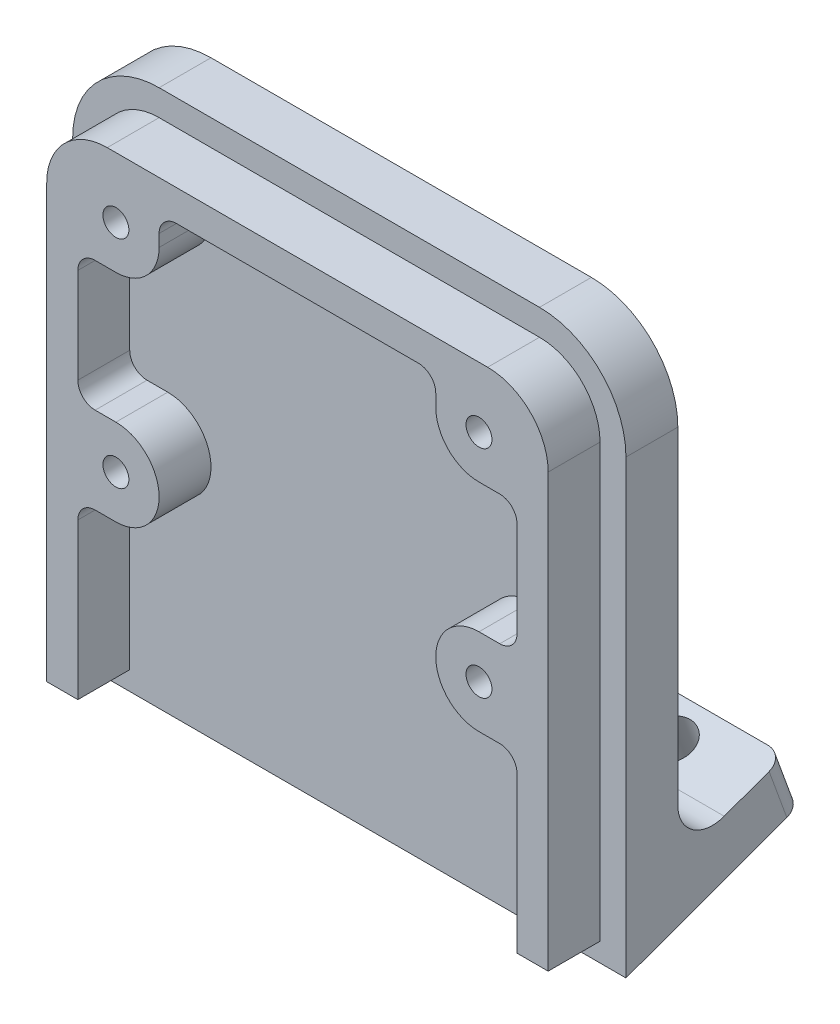
from build123d import *

# Parameters (mm, degrees)
SKETCH1_W                           = 32
SKETCH1_H                           = 30
BOSS_EXTRUDE1_DEPTH                 = 3
BOSS_EXTRUDE2_DEPTH                 = 3
F_1_5MM_CLEARANCE_DOWEL_HOLE1_D     = 1.5
F_1_5MM_CLEARANCE_DOWEL_HOLE1_DEPTH = 5
F_1_5MM_CLEARANCE_DOWEL_HOLE1_TIP   = 0.450645464
FILLET1_R                           = 5
FILLET2_R                           = 3.5
BOSS_EXTRUDE4_DEPTH                 = 32
BOSS_EXTRUDE5_DEPTH                 = 32
SKETCH8_R                           = 1.25
CUT_EXTRUDE1_DEPTH                  = 7.503603871
FILLET3_R                           = 1
FILLET4_R                           = 2
FILLET5_R                           = 1


with BuildPart() as part:
    # Sketch1 → Boss-Extrude1 (new body)
    with BuildSketch(Plane.XY):
        with Locations((16, 15)):
            Rectangle(SKETCH1_W, SKETCH1_H)
    extrude(amount=BOSS_EXTRUDE1_DEPTH)

    # Sketch2 → Boss-Extrude2 (add)
    with BuildSketch(Plane.XY.offset(3)):
        with BuildLine():
            Line((1.5, 0), (3.3, 0))
            Line((3.3, 0), (3.3, 10))
            Line((3.3, 10), (5.5, 10))
            ThreePointArc((5.5, 10), (8, 12.5), (5.5, 15))
            Line((5.5, 15), (3.3, 15))
            Line((3.3, 15), (3.3, 22.5))
            Line((3.3, 22.5), (5.5, 22.5))
            ThreePointArc((5.5, 22.5), (7.267766953, 23.232233047), (8, 25))
            Line((8, 25), (8, 26.7))
            Line((8, 26.7), (24, 26.7))
            Line((24, 26.7), (24, 25))
            ThreePointArc((24, 25), (24.732233047, 23.232233047), (26.5, 22.5))
            Line((26.5, 22.5), (28.7, 22.5))
            Line((28.7, 22.5), (28.7, 15))
            Line((28.7, 15), (26.5, 15))
            ThreePointArc((26.5, 15), (24, 12.5), (26.5, 10))
            Line((26.5, 10), (28.7, 10))
            Line((28.7, 10), (28.7, 0))
            Line((28.7, 0), (30.5, 0))
            Line((30.5, 0), (30.5, 28.5))
            Line((30.5, 28.5), (1.5, 28.5))
            Line((1.5, 28.5), (1.5, 0))
        make_face()
    extrude(amount=BOSS_EXTRUDE2_DEPTH)

    # Ø1.5mm Clearance Dowel Hole1
    with Locations(Plane(origin=(5.5, 25, 6), x_dir=(1, 0, 0), z_dir=(0, 0, 1))):
        with Locations((0, 0), (21, 0), (21, -12.5), (0, -12.5)):
            Hole(F_1_5MM_CLEARANCE_DOWEL_HOLE1_D / 2, depth=F_1_5MM_CLEARANCE_DOWEL_HOLE1_DEPTH)
            with Locations((0, 0, -(F_1_5MM_CLEARANCE_DOWEL_HOLE1_DEPTH + F_1_5MM_CLEARANCE_DOWEL_HOLE1_TIP / 2))):  # 118° drill point
                Cone(0, F_1_5MM_CLEARANCE_DOWEL_HOLE1_D / 2, F_1_5MM_CLEARANCE_DOWEL_HOLE1_TIP, mode=Mode.SUBTRACT)

    # Fillet1
    fillet1_edges = [part.edges().sort_by_distance(p)[0] for p in [
        (0, 30, 1.5),
        (32, 30, 1.5),
    ]]
    fillet(fillet1_edges, radius=FILLET1_R)

    # Fillet2
    fillet2_edges = [part.edges().sort_by_distance(p)[0] for p in [
        (1.5, 28.5, 4.5),
        (30.5, 28.5, 4.5),
    ]]
    fillet(fillet2_edges, radius=FILLET2_R)

    # Sketch5 → Boss-Extrude4 (add)
    with BuildSketch(Plane.ZY):
        Polygon((0, 0), (-7.243852416, 2.636546661), (-6.217791986, 5.455624523), (0, 3.192533317), align=None)
    extrude(amount=-BOSS_EXTRUDE4_DEPTH)

    # Sketch7 → Boss-Extrude5 (add)
    with BuildSketch(Plane.ZY):
        Polygon((0, 0), (3, -1.091910703), (3, 0), align=None)
    extrude(amount=-BOSS_EXTRUDE5_DEPTH)

    # Sketch8 → Cut-Extrude1 (cut, through all)
    with BuildSketch(Plane(origin=(0, 2.819077862, 1.02606043), x_dir=(1, 0, 0), z_dir=(0, 0.939692621, 0.342020143))):
        with Locations((4.810584477, 5.708746728)):
            Circle(SKETCH8_R)
        with Locations((27.189415523, 5.708746728)):
            Circle(SKETCH8_R)
    extrude(amount=-CUT_EXTRUDE1_DEPTH, mode=Mode.SUBTRACT)

    # Fillet3
    fillet3_edges = [part.edges().sort_by_distance(p)[0] for p in [
        (3.3, 10, 4.5),
        (3.3, 15, 4.5),
        (3.3, 22.5, 4.5),
        (8, 26.7, 4.5),
        (24, 26.7, 4.5),
        (28.7, 22.5, 4.5),
        (28.7, 15, 4.5),
        (28.7, 10, 4.5),
    ]]
    fillet(fillet3_edges, radius=FILLET3_R)

    # Fillet4
    fillet4_edges = [part.edges().sort_by_distance(p)[0] for p in [
        (16, 3.192533317, 0),
    ]]
    fillet(fillet4_edges, radius=FILLET4_R)

    # Fillet5
    fillet5_edges = [part.edges().sort_by_distance(p)[0] for p in [
        (0, 4.046085592, -6.730822201),
        (32, 4.046085592, -6.730822201),
    ]]
    fillet(fillet5_edges, radius=FILLET5_R)


solid = part.part
